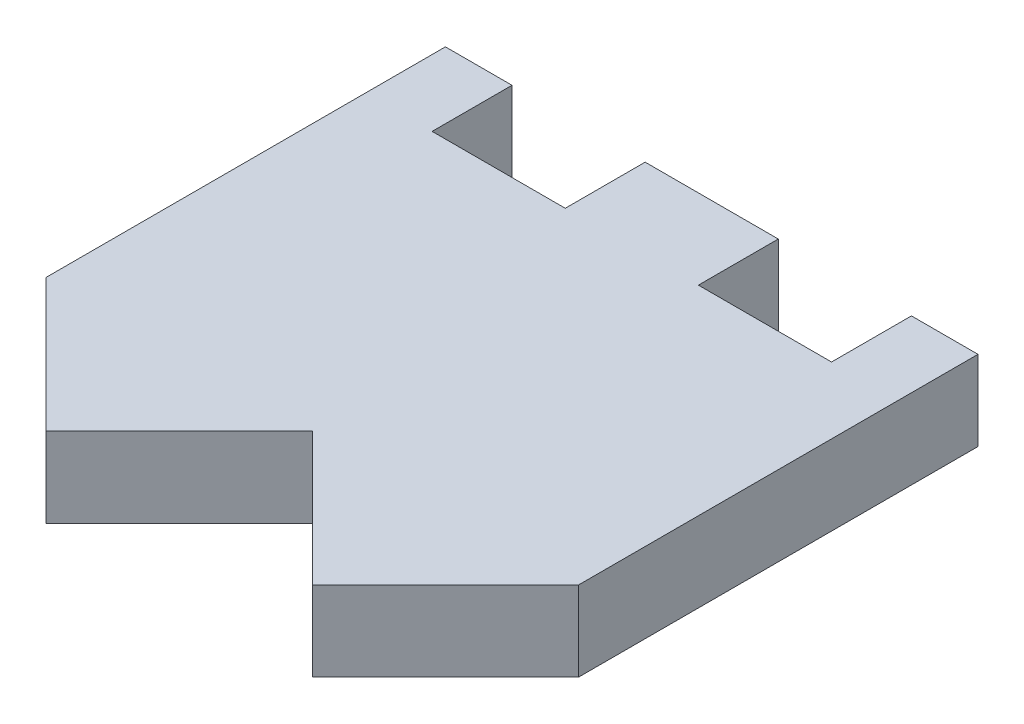
from build123d import *

# Parameters (mm, degrees)
SKETCH1_W               = 20
SKETCH1_H               = 20
BOSS_EXTRUDE1_DEPTH     = 3
CUT_EXTRUDE1_DEPTH      = 1
CUT_EXTRUDE1_DEPTH_BACK = 4
CUT_EXTRUDE2_START      = -4
SKETCH3_W               = 5
SKETCH3_H               = 3
CUT_EXTRUDE2_DEPTH      = 5


with BuildPart() as part:
    # Sketch1 → Boss-Extrude1 (new body)
    with BuildSketch(Plane(origin=(0, 0, 0), x_dir=(1, 0, 0), z_dir=(0, 1, 0))):
        Rectangle(SKETCH1_W, SKETCH1_H)
    extrude(amount=BOSS_EXTRUDE1_DEPTH)

    # Sketch2 → Cut-Extrude1 (cut, two sides)
    with BuildSketch(Plane(origin=(0, 3, 0), x_dir=(1, 0, 0), z_dir=(0, 1, 0))) as cut_extrude1_sk:
        Polygon((-5, -10), (-10, -5), (-10, -10), align=None)
        Polygon((0, -5), (-5, -10), (5, -10), align=None)
        Polygon((10, -5), (5, -10), (10, -10), align=None)
    extrude(amount=CUT_EXTRUDE1_DEPTH, mode=Mode.SUBTRACT)
    extrude(cut_extrude1_sk.sketch, amount=-CUT_EXTRUDE1_DEPTH_BACK, mode=Mode.SUBTRACT)

    # Sketch3 → Cut-Extrude2 (cut)
    with BuildSketch(Plane(origin=(0, 3, 0), x_dir=(1, 0, 0), z_dir=(0, 1, 0)).offset(CUT_EXTRUDE2_START)):
        with Locations((-5, 8.5)):
            Rectangle(SKETCH3_W, SKETCH3_H)
    cut_extrude2 = extrude(amount=CUT_EXTRUDE2_DEPTH, mode=Mode.SUBTRACT)

    # Mirror1: Cut-Extrude2 across plane
    add(cut_extrude2.mirror(Plane(origin=(0, 0, 0), x_dir=(0, 0, 1), z_dir=(1, 0, 0))), mode=Mode.SUBTRACT)


solid = part.part
